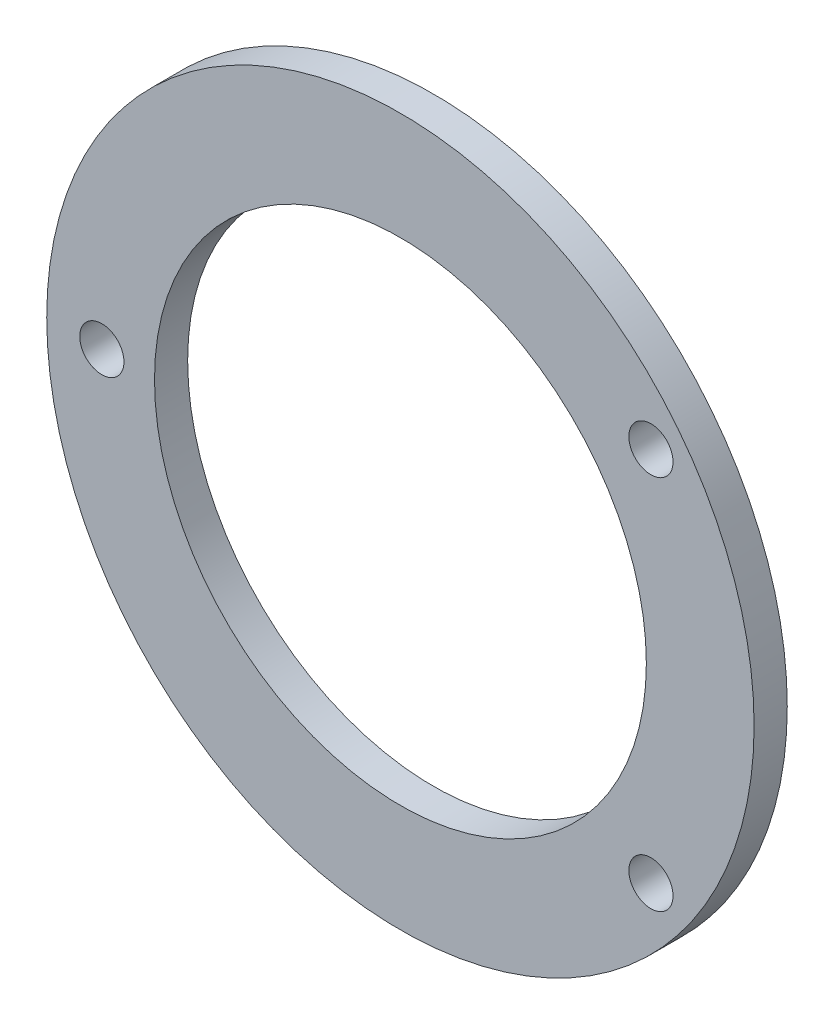
from build123d import *

# Parameters (mm, degrees)
SKETCH1_R           = 64
SKETCH1_R_2         = 44.5
SKETCH1_R_3         = 4
BOSS_EXTRUDE1_DEPTH = 6


with BuildPart() as part:
    # Sketch1 → Boss-Extrude1 (new body)
    with BuildSketch(Plane.XY):
        with Locations((-2.310524051, 2.621697373)):
            Circle(SKETCH1_R)
        with Locations((-2.310524051, 2.621697373)):
            Circle(SKETCH1_R_2, mode=Mode.SUBTRACT)
        with Locations((43.019475949, -31.378302627)):
            Circle(SKETCH1_R_3, mode=Mode.SUBTRACT)
        with Locations((43.019475949, 36.621697373)):
            Circle(SKETCH1_R_3, mode=Mode.SUBTRACT)
        with Locations((-56.340524051, 2.621697373)):
            Circle(SKETCH1_R_3, mode=Mode.SUBTRACT)
    extrude(amount=BOSS_EXTRUDE1_DEPTH)


solid = part.part
